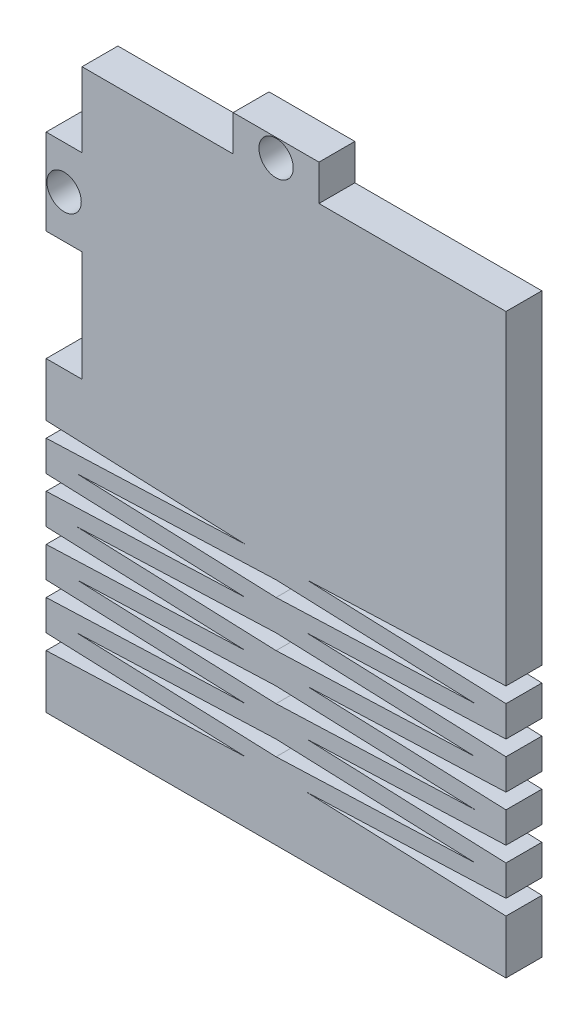
from build123d import *

# Parameters (mm, degrees)
SKETCH1_R           = 1.4224
BOSS_EXTRUDE7_DEPTH = 2.9718


with BuildPart() as part:
    # Sketch1 → Boss-Extrude7 (new body)
    with BuildSketch(Plane.XY):
        Polygon((15.494, 22.4282), (2.9718, 22.4282), (2.9718, 16.256), (0, 16.256), (0, 9.144), (2.9718, 9.144), (2.9718, 0), (0, 0), (0, -4.445), (16.51, -5.08), (0, -5.715), (0, -8.255), (16.51, -8.89), (0, -9.525), (0, -12.065), (16.51, -12.7), (0, -13.335), (0, -15.875), (16.51, -16.51), (0, -17.145), (0, -19.685), (16.51, -20.32), (0, -20.955), (0, -25.4), (38.1, -25.4), (38.1, -20.955), (21.59, -20.32), (38.1, -19.685), (38.1, -17.145), (21.59, -16.51), (38.1, -15.875), (38.1, -13.335), (21.59, -12.7), (38.1, -12.065), (38.1, -9.525), (21.59, -8.89), (38.1, -8.255), (38.1, -5.715), (21.59, -5.08), (38.1, -4.445), (38.1, 22.4282), (22.606, 22.4282), (22.606, 25.4), (15.494, 25.4), align=None)
        with Locations((1.4859, 12.7)):
            Circle(SKETCH1_R, mode=Mode.SUBTRACT)
        with Locations((19.05, 23.9141)):
            Circle(SKETCH1_R, mode=Mode.SUBTRACT)
        Polygon((2.54, -6.985), (19.05, -6.35), (35.56, -6.985), (19.05, -7.62), align=None, mode=Mode.SUBTRACT)
        Polygon((19.05, -19.05), (2.54, -18.415), (19.05, -17.78), (35.56, -18.415), align=None, mode=Mode.SUBTRACT)
        Polygon((19.05, -13.97), (35.56, -14.605), (19.05, -15.24), (2.54, -14.605), align=None, mode=Mode.SUBTRACT)
        Polygon((19.05, -10.16), (35.56, -10.795), (19.05, -11.43), (2.54, -10.795), align=None, mode=Mode.SUBTRACT)
    extrude(amount=BOSS_EXTRUDE7_DEPTH)


solid = part.part
